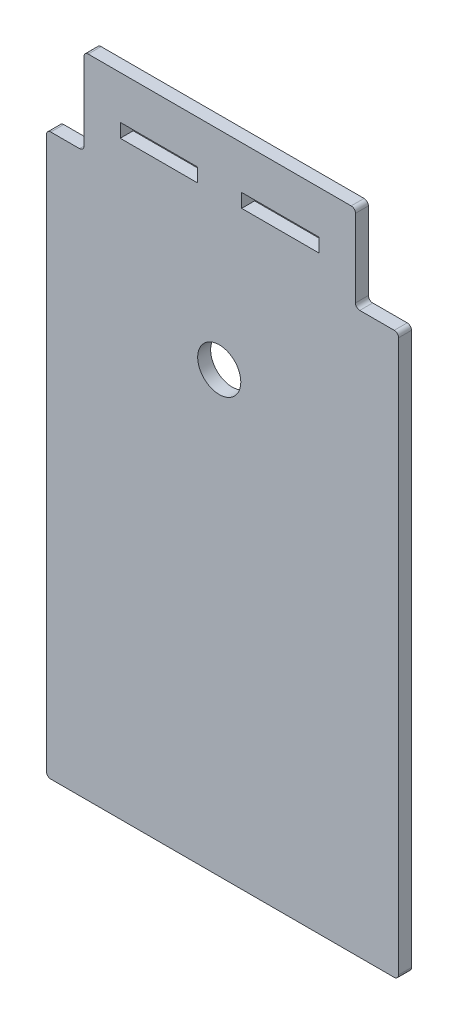
from build123d import *

# Parameters (mm, degrees)
MODEL_R                 = 5
MODEL_W                 = 17.963611368
MODEL_H                 = 3.2
MODEL_W_2               = 17.963611367
SALIENTE_EXTRUIR1_DEPTH = 3


with BuildPart() as part:
    # Model → Saliente-Extruir1 (new body)
    with BuildSketch(Plane.XY):
        with BuildLine():
            Line((64.163611368, -39.615377633), (64.163611368, -4))
            Line((64.163611368, -4), (64.163611368, 15.5))
            Line((64.163611368, 15.5), (64.163611368, 34))
            ThreePointArc((64.163611368, 34), (64.456504586, 34.707106781), (65.163611368, 35))
            Line((65.163611368, 35), (71.836388632, 35))
            ThreePointArc((71.836388632, 35), (72.543495414, 35.292893219), (72.836388632, 36))
            Line((72.836388632, 36), (72.836388632, 54))
            ThreePointArc((72.836388632, 54), (73.129281851, 54.707106781), (73.836388632, 55))
            Line((73.836388632, 55), (134.836388632, 55))
            ThreePointArc((134.836388632, 55), (135.543495414, 54.707106781), (135.836388632, 54))
            Line((135.836388632, 54), (135.836388632, 36))
            ThreePointArc((135.836388632, 36), (136.129281851, 35.292893219), (136.836388632, 35))
            Line((136.836388632, 35), (144.836388632, 35))
            ThreePointArc((144.836388632, 35), (145.543495414, 34.707106781), (145.836388632, 34))
            Line((145.836388632, 34), (145.836388632, -94))
            ThreePointArc((145.836388632, -94), (145.543495414, -94.707106781), (144.836388632, -95))
            Line((144.836388632, -95), (65.163611368, -95))
            ThreePointArc((65.163611368, -95), (64.456504586, -94.707106781), (64.163611368, -94))
            Line((64.163611368, -94), (64.163611368, -39.615377633))
        make_face()
        with Locations((104.236388632, 6.8)):
            Circle(MODEL_R, mode=Mode.SUBTRACT)
        with Locations((118.418194316, 43.4)):
            Rectangle(MODEL_W, MODEL_H, mode=Mode.SUBTRACT)
        with Locations((90.254582949, 43.4)):
            Rectangle(MODEL_W_2, MODEL_H, mode=Mode.SUBTRACT)
    extrude(amount=SALIENTE_EXTRUIR1_DEPTH)


solid = part.part
